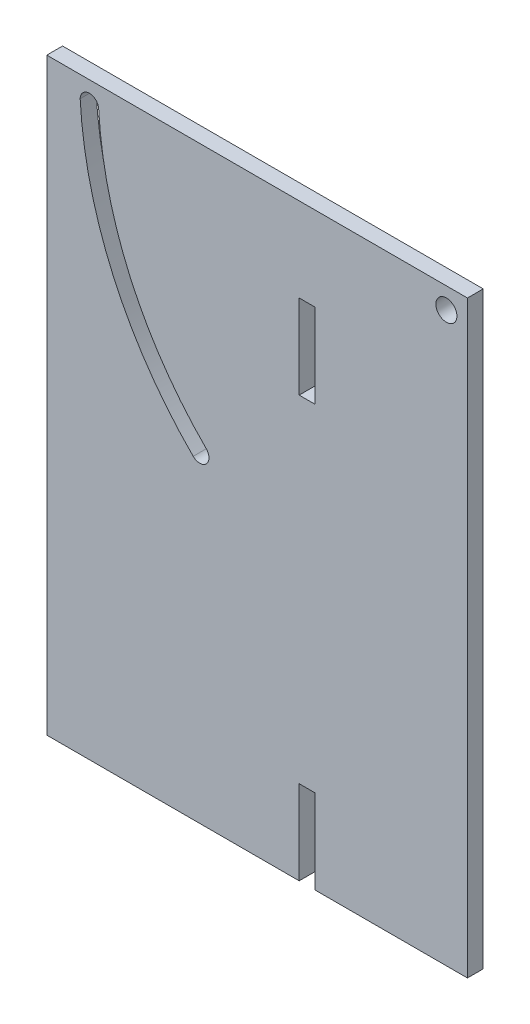
from build123d import *

# Parameters (mm, degrees)
SKETCH1_R           = 3.175
SKETCH1_W           = 4.7625
SKETCH1_H           = 25.4
BOSS_EXTRUDE1_DEPTH = 4.7625


with BuildPart() as part:
    # Sketch1 → Boss-Extrude1 (new body)
    with BuildSketch(Plane.XY):
        Polygon((80.9625, 0), (127, 0), (127, 177.8), (0, 177.8), (0, 0), (76.2, 0), (76.2, 25.4), (80.9625, 25.4), align=None)
        with Locations((120.65, 171.45)):
            Circle(SKETCH1_R, mode=Mode.SUBTRACT)
        with Locations((78.58125, 139.7)):
            Rectangle(SKETCH1_W, SKETCH1_H, mode=Mode.SUBTRACT)
        with BuildLine():
            ThreePointArc((10.07830682, 171.45), (20.074522157, 130.072156721), (44.202038564, 95.002038564))
            ThreePointArc((44.202038564, 95.002038564), (48.153351257, 95.002038564), (48.153351257, 98.953351257))
            ThreePointArc((48.153351257, 98.953351257), (25.239205738, 132.21130856), (15.674955486, 171.45))
            ThreePointArc((15.674955486, 171.45), (12.876631153, 174.248324333), (10.07830682, 171.45))
        make_face(mode=Mode.SUBTRACT)
    extrude(amount=BOSS_EXTRUDE1_DEPTH)


solid = part.part
